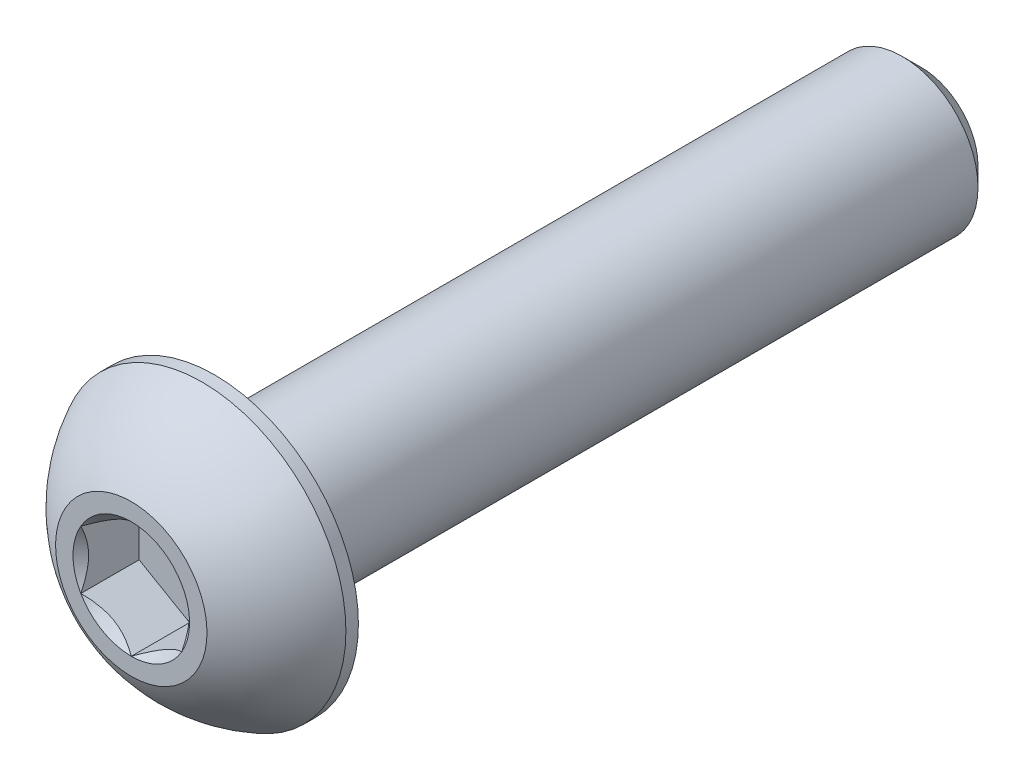
from build123d import *

# Parameters (mm, degrees)
CUT_EXTRUDE2_DEPTH = 1.155


with BuildPart() as part:
    # Sketch10 → Revolve3 (revolve)
    with BuildSketch(Plane(origin=(0, 0, 0), x_dir=(0, 0, -1), z_dir=(1, 0, 0))):
        Polygon((15.275, 1.5), (15.65, 1.125), (15.65, 0), (1.65, 0), (1.65, 1.5), align=None)
    revolve(axis=Axis((0, 0, 0), (0, 0, -1)))

    # Sketch7 → Revolve2 (revolve)
    with BuildSketch(Plane(origin=(0, 0, 0), x_dir=(0, 0, -1), z_dir=(1, 0, 0))):
        with BuildLine():
            Line((1.4025, 2.85), (1.65, 2.85))
            Line((1.65, 2.85), (1.65, 0))
            Line((1.65, 0), (0, 0))
            Line((0, 0), (0, 1.5))
            ThreePointArc((0, 1.5), (0.59512511, 2.285251969), (1.4025, 2.85))
        make_face()
    revolve(axis=Axis((0, 0, 0), (0, 0, -1)))

    # Sketch5 → Cut-Extrude2 (cut)
    with BuildSketch(Plane.XY):
        Polygon((1, -0.577350269), (1, 0.577350269), (0, 1.154700538), (-1, 0.577350269), (-1, -0.577350269), (0, -1.154700538), align=None)
    extrude(amount=-CUT_EXTRUDE2_DEPTH, mode=Mode.SUBTRACT)

    # Cut-Extrude3 cone 1 section (through the dimple's axis) → Cut-Extrude3 (revolve, cut)
    with BuildSketch(Plane(origin=(0, 0, 0), x_dir=(0, -1, 0), z_dir=(1, 0, 0))):
        Polygon((0, 0), (1.154700538, 0), (0, 1.154700538), align=None)
    revolve(axis=Axis((0, 0, 0), (0, 0, -1)), mode=Mode.SUBTRACT)


solid = part.part
